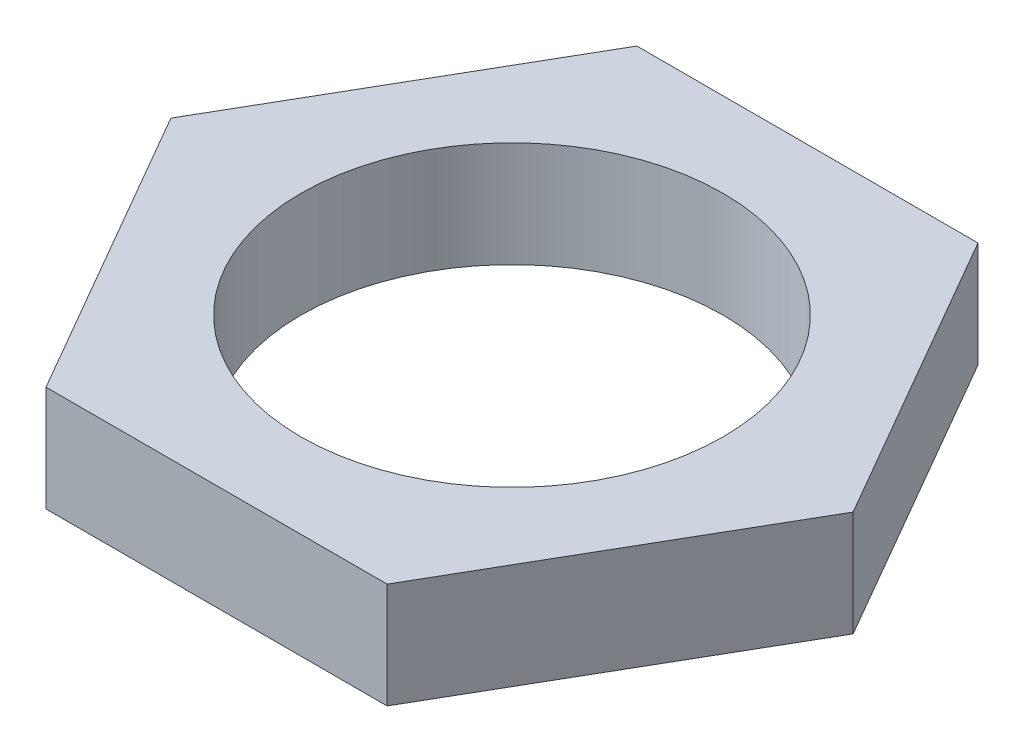
from build123d import *

# Parameters (mm, degrees)
SKETCH1_R           = 5
BOSS_EXTRUDE1_DEPTH = 1.25


with BuildPart() as part:
    # Sketch1 → Boss-Extrude1 (new body, symmetric)
    with BuildSketch(Plane(origin=(0, 0, 0), x_dir=(1, 0, 0), z_dir=(0, 1, 0))):
        Polygon((8.082903769, 0), (4.041451884, 7), (-4.041451884, 7), (-8.082903769, 0), (-4.041451884, -7), (4.041451884, -7), align=None)
        Circle(SKETCH1_R, mode=Mode.SUBTRACT)
    extrude(amount=BOSS_EXTRUDE1_DEPTH, both=True)


solid = part.part
